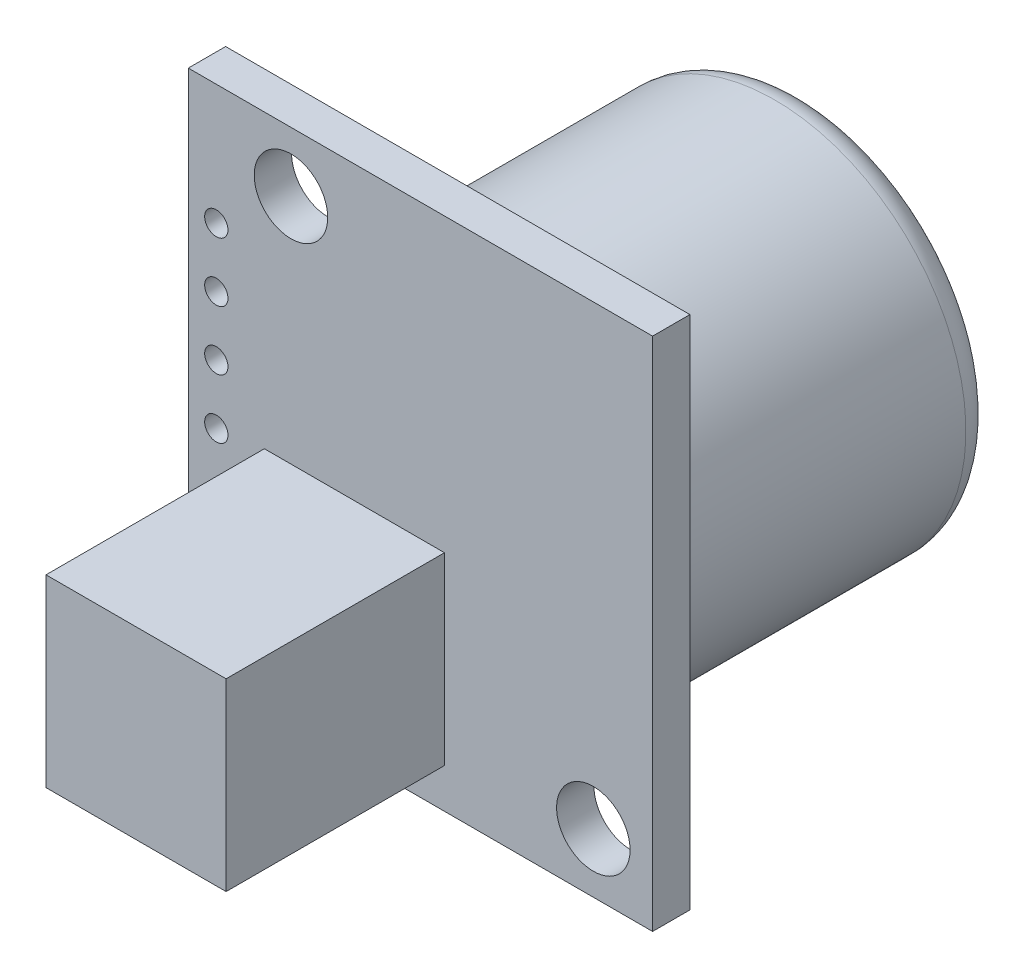
from build123d import *

# Parameters (mm, degrees)
SKETCH1_W           = 19.9
SKETCH1_H           = 22.1
SKETCH1_R           = 1.5748
SKETCH1_R_2         = 0.5
BOSS_EXTRUDE1_DEPTH = 1.6
SKETCH2_R           = 8.2
BOSS_EXTRUDE2_DEPTH = 13.9192
FILLET2_R           = 1.27
SKETCH3_W           = 7.72
SKETCH3_H           = 7.9
BOSS_EXTRUDE3_DEPTH = 9.36


with BuildPart() as part:
    # Sketch1 → Boss-Extrude1 (new body)
    with BuildSketch(Plane.XY):
        Rectangle(SKETCH1_W, SKETCH1_H)
        with Locations((-5.55, 8.49)):
            Circle(SKETCH1_R, mode=Mode.SUBTRACT)
        with Locations((7.41, -8.51)):
            Circle(SKETCH1_R, mode=Mode.SUBTRACT)
        with Locations((-8.75, -9.35)):
            Circle(SKETCH1_R_2, mode=Mode.SUBTRACT)
        with Locations((-8.75, -6.81)):
            Circle(SKETCH1_R_2, mode=Mode.SUBTRACT)
        with Locations((-8.75, -4.27)):
            Circle(SKETCH1_R_2, mode=Mode.SUBTRACT)
        with Locations((-8.75, -1.73)):
            Circle(SKETCH1_R_2, mode=Mode.SUBTRACT)
        with Locations((-8.75, 0.81)):
            Circle(SKETCH1_R_2, mode=Mode.SUBTRACT)
        with Locations((-8.75, 3.35)):
            Circle(SKETCH1_R_2, mode=Mode.SUBTRACT)
        with Locations((-8.75, 5.89)):
            Circle(SKETCH1_R_2, mode=Mode.SUBTRACT)
    extrude(amount=BOSS_EXTRUDE1_DEPTH)

    # Sketch2 → Boss-Extrude2 (add)
    with BuildSketch(Plane(origin=(0, 0, 0), x_dir=(-1, 0, 0), z_dir=(0, 0, -1))):
        with Locations((-0.93, -0.01)):
            Circle(SKETCH2_R)
    extrude(amount=BOSS_EXTRUDE2_DEPTH)

    # Fillet2
    fillet2_edges = [part.edges().sort_by_distance(p)[0] for p in [
        (9.13, -0.01, -13.9192),
    ]]
    fillet(fillet2_edges, radius=FILLET2_R)

    # Sketch3 → Boss-Extrude3 (add)
    with BuildSketch(Plane.XY.offset(1.6)):
        with Locations((-2.83, -5.4)):
            Rectangle(SKETCH3_W, SKETCH3_H)
    extrude(amount=BOSS_EXTRUDE3_DEPTH)


solid = part.part
